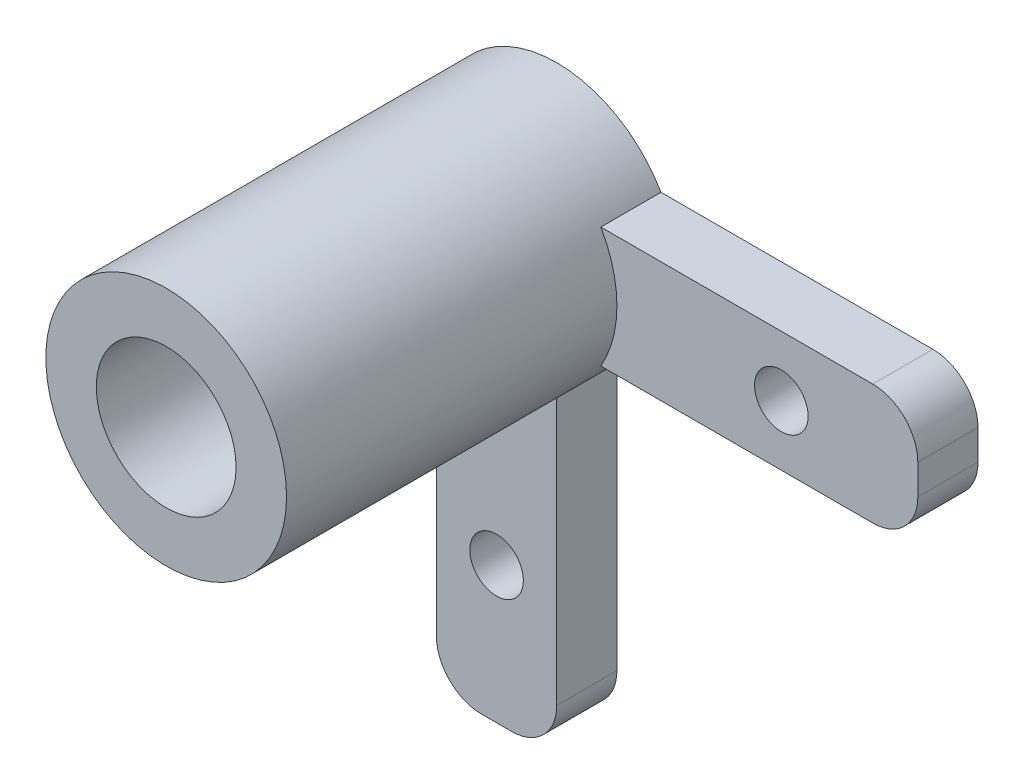
from build123d import *

# Parameters (mm, degrees)
EXTRUDE2_DEPTH                  = 2.54
SKETCH5_R                       = 5.08
EXTRUDE3_DEPTH                  = 13.9446
EXTRUDE3_DEPTH_BACK             = 2.54
F_43_0_089_DIAMETER_HOLE1_D     = 2.2606
F_43_0_089_DIAMETER_HOLE1_DEPTH = 5.08
F_43_0_089_DIAMETER_HOLE1_TIP   = 0.679152758
SKETCH11_R                      = 2.95
EXTRUDE11_DEPTH                 = 17.4846
FILLET1_R                       = 1.905


with BuildPart() as part:
    # Sketch4 → Extrude2 (new body)
    with BuildSketch(Plane.XY):
        Polygon((-30.111603353, 27.840609557), (-51.701603353, 27.840609557), (-51.701603353, 22.760609557), (-50.431603353, 22.760609557), (-50.431603353, 7.520609557), (-45.351603353, 7.520609557), (-45.351603353, 22.760609557), (-30.111603353, 22.760609557), align=None)
    extrude(amount=EXTRUDE2_DEPTH)

    # Sketch5 → Extrude3 (add, two sides)
    with BuildSketch(Plane.XY.offset(2.54)) as extrude3_sk:
        with Locations((-47.891603353, 25.300609557)):
            Circle(SKETCH5_R)
    extrude(amount=EXTRUDE3_DEPTH)
    extrude(extrude3_sk.sketch, amount=-EXTRUDE3_DEPTH_BACK)

    # #43 (0.089) Diameter Hole1
    with Locations(Plane(origin=(-47.891603353, 13.281329557, 2.54), x_dir=(1, 0, 0), z_dir=(0, 0, 1))):
        with Locations((0, 0), (12.01928, 12.01928)):
            Hole(F_43_0_089_DIAMETER_HOLE1_D / 2, depth=F_43_0_089_DIAMETER_HOLE1_DEPTH)
            with Locations((0, 0, -(F_43_0_089_DIAMETER_HOLE1_DEPTH + F_43_0_089_DIAMETER_HOLE1_TIP / 2))):  # 118° drill point
                Cone(0, F_43_0_089_DIAMETER_HOLE1_D / 2, F_43_0_089_DIAMETER_HOLE1_TIP, mode=Mode.SUBTRACT)

    # Sketch11 → Extrude11 (cut, through all)
    with BuildSketch(Plane.XY.offset(16.4846)):
        with Locations((-47.891603353, 25.300609557)):
            Circle(SKETCH11_R)
    extrude(amount=-EXTRUDE11_DEPTH, mode=Mode.SUBTRACT)

    # Fillet1
    fillet1_edges = [part.edges().sort_by_distance(p)[0] for p in [
        (-30.111603353, 22.760609557, 1.27),
        (-45.351603353, 7.520609557, 1.27),
        (-50.431603353, 7.520609557, 1.27),
        (-30.111603353, 27.840609557, 1.27),
    ]]
    fillet(fillet1_edges, radius=FILLET1_R)


solid = part.part
